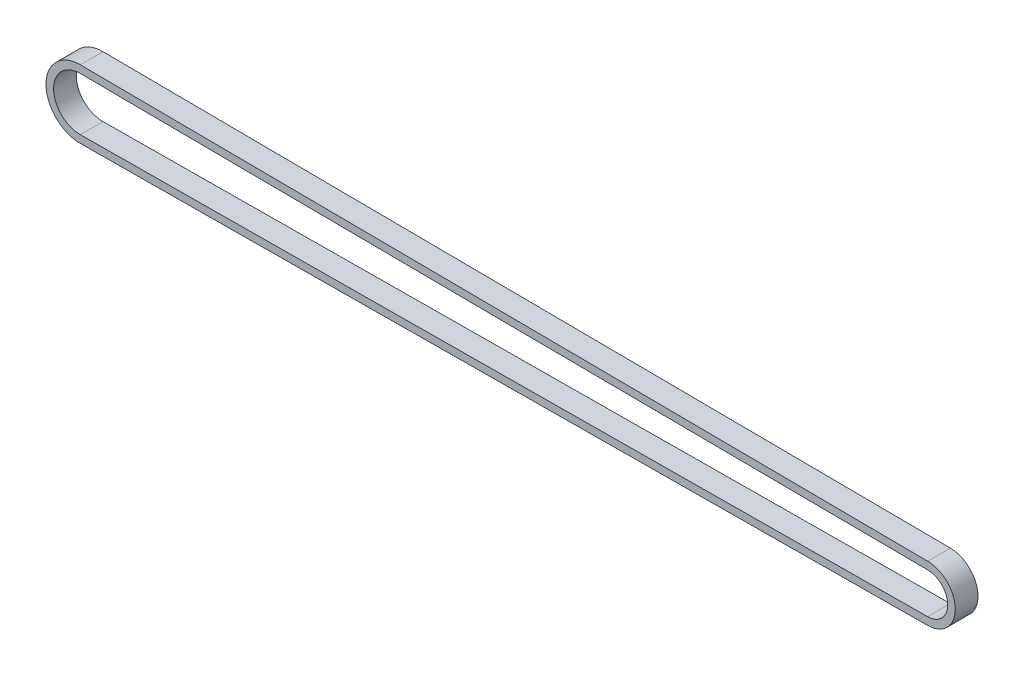
from build123d import *

# Parameters (mm, degrees)
BOSS_EXTRUDE1_DEPTH = 6


with BuildPart() as part:
    # Sketch1 → Boss-Extrude1 (new body)
    with BuildSketch(Plane.XY):
        with BuildLine():
            Line((112.877273452, -7.353354748), (-111.110624823, -8.999756882))
            ThreePointArc((-111.110624823, -8.999756882), (-120.176776695, 0), (-111.110624823, 8.999756882))
            Line((-111.110624823, 8.999756882), (112.877273452, 7.353354748))
            ThreePointArc((112.877273452, 7.353354748), (120.176776695, 0), (112.877273452, -7.353354748))
        make_face()
        with BuildLine():
            Line((112.862573036, -5.353408774), (-111.125325239, -6.999810908))
            ThreePointArc((-111.125325239, -6.999810908), (-118.176776695, 0), (-111.125325239, 6.999810908))
            Line((-111.125325239, 6.999810908), (112.862573036, 5.353408774))
            ThreePointArc((112.862573036, 5.353408774), (118.176776695, 0), (112.862573036, -5.353408774))
        make_face(mode=Mode.SUBTRACT)
    extrude(amount=BOSS_EXTRUDE1_DEPTH)


solid = part.part
